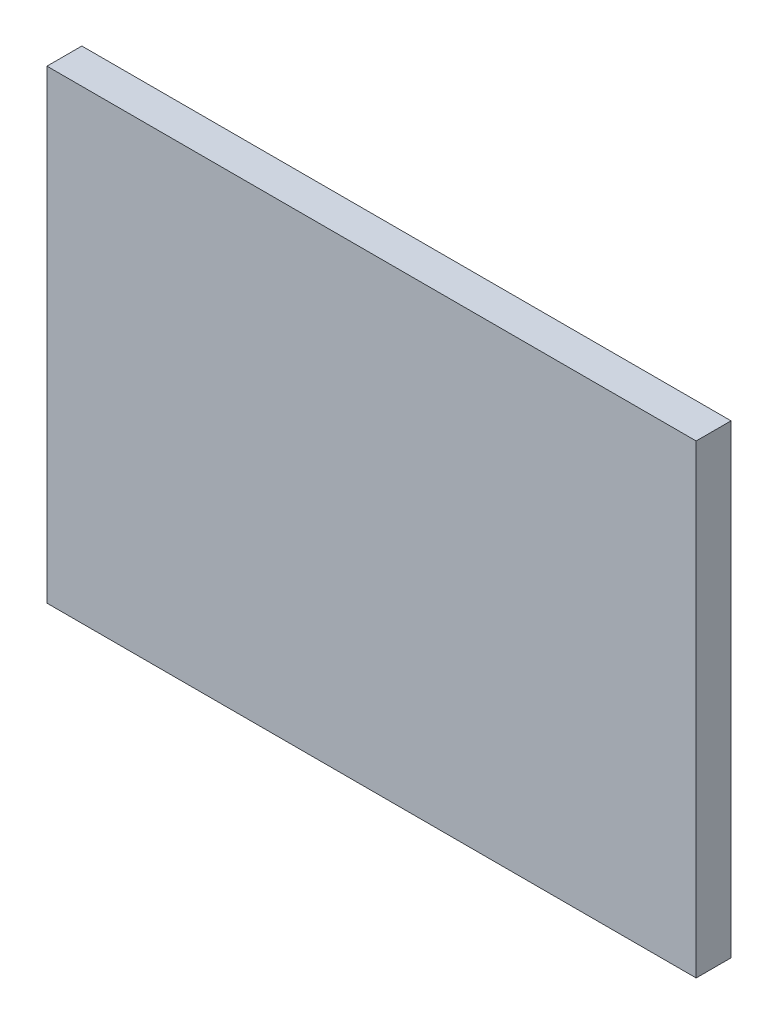
from build123d import *

# Parameters (mm, degrees)
SIDEOUTLINE_W               = 212.725
SIDEOUTLINE_H               = 152.4
SIDEOUTLINE_THICKNESS_DEPTH = 11.43


with BuildPart() as part:
    # SideOutline → SideOutline_Thickness (new body)
    with BuildSketch(Plane.XY):
        with Locations((-4872.0375, 1295.4)):
            Rectangle(SIDEOUTLINE_W, SIDEOUTLINE_H)
    extrude(amount=-SIDEOUTLINE_THICKNESS_DEPTH)


solid = part.part
